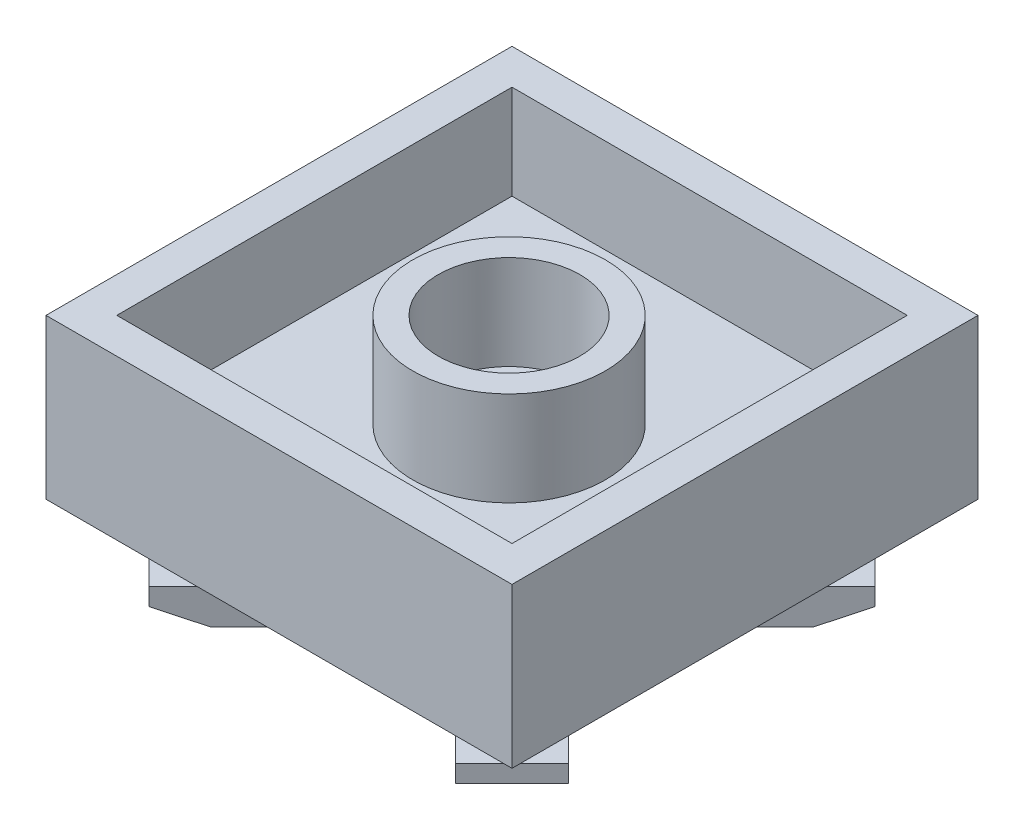
from build123d import *

# Parameters (mm, degrees)
SKETCH2_W            = 15.8
SKETCH2_H            = 15.8
BOSS_EXTRUDE2_DEPTH  = 5.4
SKETCH4_W            = 13.4
SKETCH4_H            = 13.4
CUT_EXTRUDE1_DEPTH   = 3.2
SKETCH7_R            = 3.265
SKETCH7_R_2          = 2.4
BOSS_EXTRUDE5_DEPTH  = 3.2
SKETCH8_R            = 5.15
CUT_EXTRUDE2_DEPTH   = 0.3
BOSS_EXTRUDE8_DEPTH  = 2.8
SKETCH27_W           = 2.7
SKETCH27_H           = 1.2
BOSS_EXTRUDE10_DEPTH = 1.2
CUT_EXTRUDE3_DEPTH   = 2.7
CIRPATTERN1_COUNT    = 4


with BuildPart() as part:
    # Sketch2 → Boss-Extrude2 (new body)
    with BuildSketch(Plane(origin=(0, 0, 0), x_dir=(1, 0, 0), z_dir=(0, 1, 0))):
        with Locations((7.9, 7.9)):
            Rectangle(SKETCH2_W, SKETCH2_H)
    extrude(amount=-BOSS_EXTRUDE2_DEPTH)

    # Sketch4 → Cut-Extrude1 (cut)
    with BuildSketch(Plane(origin=(0, 0, 0), x_dir=(1, 0, 0), z_dir=(0, 1, 0))):
        with Locations((7.9, 7.9)):
            Rectangle(SKETCH4_W, SKETCH4_H)
    extrude(amount=-CUT_EXTRUDE1_DEPTH, mode=Mode.SUBTRACT)

    # Sketch7 → Boss-Extrude5 (add)
    with BuildSketch(Plane(origin=(0, -3.2, 0), x_dir=(1, 0, 0), z_dir=(0, 1, 0))):
        with Locations((7.85, 7.85)):
            Circle(SKETCH7_R)
        with Locations((7.85, 7.85)):
            Circle(SKETCH7_R_2, mode=Mode.SUBTRACT)
    extrude(amount=BOSS_EXTRUDE5_DEPTH)

    # Sketch8 → Cut-Extrude2 (cut)
    with BuildSketch(Plane(origin=(0, -5.4, 0), x_dir=(-1, 0, 0), z_dir=(0, -1, 0))):
        with Locations((-7.9, 7.9)):
            Circle(SKETCH8_R)
    extrude(amount=-CUT_EXTRUDE2_DEPTH, mode=Mode.SUBTRACT)

    # Sketch11 → Boss-Extrude8 (add)
    with BuildSketch(Plane.XZ.offset(5.4)):
        Polygon((11.683021279, -2.207790411), (12.637615434, -3.162384566), (13.203300859, -2.596699141), (12.248706704, -1.642104986), align=None)
        with BuildLine():
            ThreePointArc((11.585853022, -2.304958669), (12.133497372, -2.706975833), (12.637615434, -3.162384566))
            Line((12.637615434, -3.162384566), (11.683021279, -2.207790411))
            Line((11.683021279, -2.207790411), (11.585853022, -2.304958669))
        make_face()
        with BuildLine():
            ThreePointArc((10.459662524, -3.431149167), (11.028098464, -3.808851017), (11.541599923, -4.258400077))
            Line((11.541599923, -4.258400077), (12.637615434, -3.162384566))
            ThreePointArc((12.637615434, -3.162384566), (12.133497372, -2.706975833), (11.585853022, -2.304958669))
            Line((11.585853022, -2.304958669), (10.459662524, -3.431149167))
        make_face()
        with BuildLine():
            Line((12.637615434, -3.162384566), (11.541599923, -4.258400077))
            ThreePointArc((11.541599923, -4.258400077), (11.991148983, -4.771901536), (12.368850833, -5.340337476))
            Line((12.368850833, -5.340337476), (13.495041331, -4.214146978))
            ThreePointArc((13.495041331, -4.214146978), (13.093024167, -3.666502628), (12.637615434, -3.162384566))
        make_face()
        with BuildLine():
            Line((13.592209589, -4.116978721), (12.637615434, -3.162384566))
            ThreePointArc((12.637615434, -3.162384566), (13.093024167, -3.666502628), (13.495041331, -4.214146978))
            Line((13.495041331, -4.214146978), (13.592209589, -4.116978721))
        make_face()
        Polygon((13.203300859, -2.596699141), (12.637615434, -3.162384566), (13.592209589, -4.116978721), (14.157895014, -3.551293296), align=None)
    boss_extrude8 = extrude(amount=BOSS_EXTRUDE8_DEPTH)

    # Sketch27 → Boss-Extrude10 (add)
    with BuildSketch(Plane(origin=(5.303300859, 0, 5.303300859), x_dir=(0.707106781, 0, -0.707106781), z_dir=(0.707106781, 0, 0.707106781))):
        with Locations((11.172287143, -7.6)):
            Rectangle(SKETCH27_W, SKETCH27_H)
    boss_extrude10 = extrude(amount=BOSS_EXTRUDE10_DEPTH)

    # Sketch28 → Cut-Extrude3 (cut)
    with BuildSketch(Plane(origin=(6.945405845, 0, -6.945405845), x_dir=(0.707106781, 0, 0.707106781), z_dir=(-0.707106781, 0, 0.707106781))):
        Polygon((8.7, -7.6), (7.215606324, -8.2), (8.7, -8.2), align=None)
    cut_extrude3 = extrude(amount=-CUT_EXTRUDE3_DEPTH, mode=Mode.SUBTRACT)

    # CirPattern1: Boss-Extrude8, Boss-Extrude10, Cut-Extrude3 ×4 about axis
    cirpattern1_axis = Axis((7.9, 0, -7.9), (0, 1, 0))
    for i in range(1, CIRPATTERN1_COUNT):
        add(boss_extrude8.rotate(cirpattern1_axis, i * 360 / CIRPATTERN1_COUNT))
        add(boss_extrude10.rotate(cirpattern1_axis, i * 360 / CIRPATTERN1_COUNT))
        add(cut_extrude3.rotate(cirpattern1_axis, i * 360 / CIRPATTERN1_COUNT), mode=Mode.SUBTRACT)


solid = part.part
